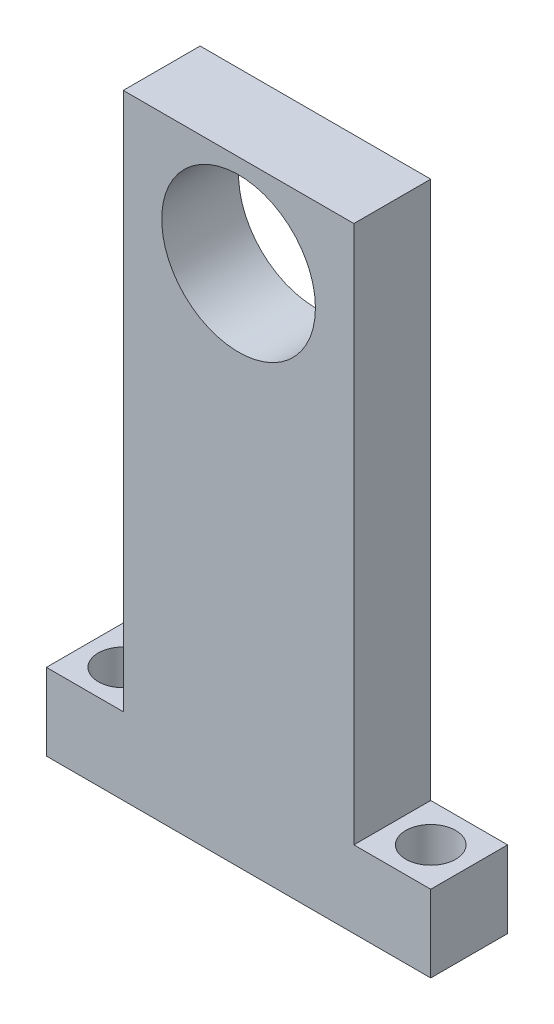
from build123d import *

# Parameters (mm, degrees)
SKETCH1_W           = 30
SKETCH1_H           = 80
SKETCH1_R           = 10
BOSS_EXTRUDE1_DEPTH = 5
SKETCH2_W           = 10
SKETCH2_H           = 10
SKETCH2_R           = 3.25
BOSS_EXTRUDE2_DEPTH = 10


with BuildPart() as part:
    # Sketch1 → Boss-Extrude1 (new body, symmetric)
    with BuildSketch(Plane.XY):
        Rectangle(SKETCH1_W, SKETCH1_H)
        with Locations((0, 28)):
            Circle(SKETCH1_R, mode=Mode.SUBTRACT)
    extrude(amount=BOSS_EXTRUDE1_DEPTH, both=True)

    # Sketch2 → Boss-Extrude2 (add)
    with BuildSketch(Plane.XZ.offset(40)):
        with Locations((20, 0)):
            Rectangle(SKETCH2_W, SKETCH2_H)
        with Locations((20, 0)):
            Circle(SKETCH2_R, mode=Mode.SUBTRACT)
    boss_extrude2 = extrude(amount=-BOSS_EXTRUDE2_DEPTH)

    # Mirror1: Boss-Extrude2 across plane
    add(boss_extrude2.mirror(Plane(origin=(0, 0, 0), x_dir=(0, 0, 1), z_dir=(1, 0, 0))))


solid = part.part
